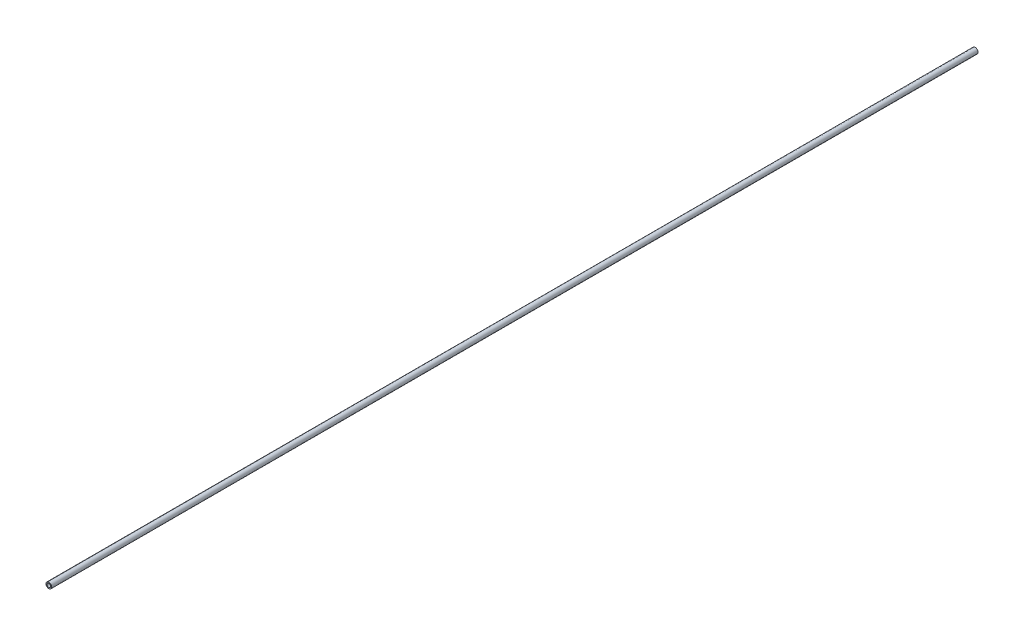
from build123d import *

# Parameters (mm, degrees)
PIPESKETCH_R    = 16.764
PIPESKETCH_R_2  = 10.414
EXTRUSION_DEPTH = 5486.4


with BuildPart() as part:
    # PipeSketch → Extrusion (new body)
    with BuildSketch(Plane.XY):
        Circle(PIPESKETCH_R)
        Circle(PIPESKETCH_R_2, mode=Mode.SUBTRACT)
    extrude(amount=EXTRUSION_DEPTH)


solid = part.part
